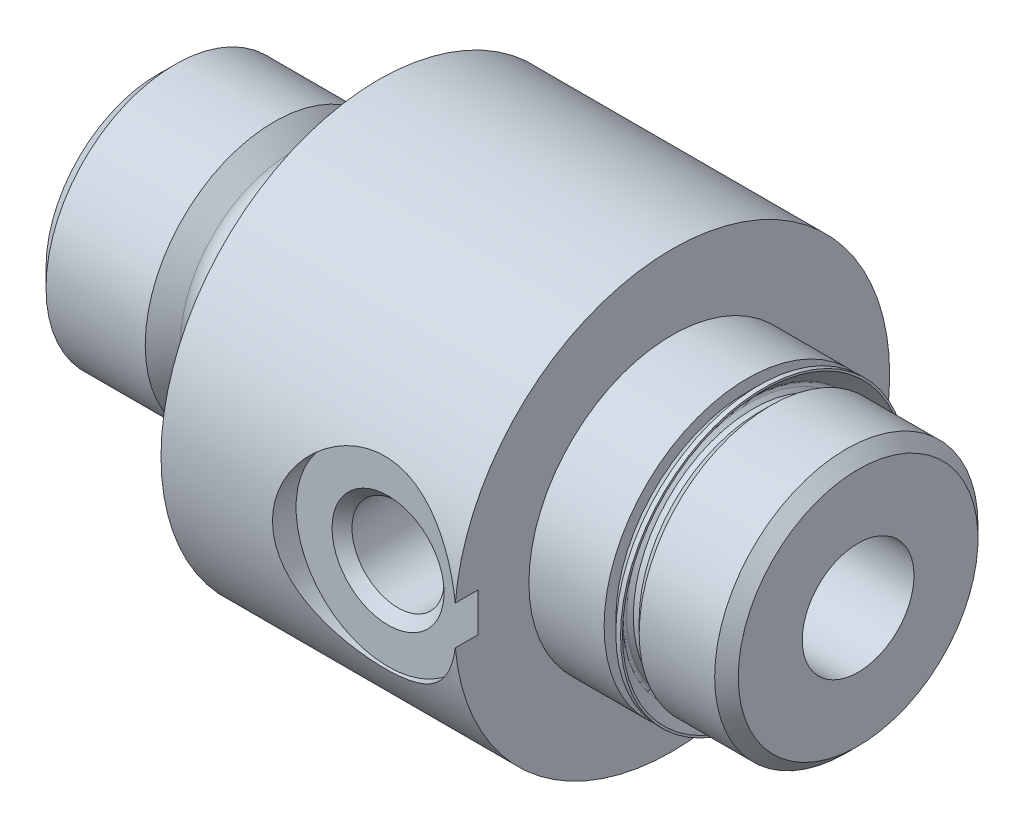
from build123d import *

# Parameters (mm, degrees)
SKETCH5_W = 3.2385
SKETCH5_H = 3.81


with BuildPart() as part:
    # Sketch1 → Revolve1 (revolve)
    with BuildSketch(Plane.XY):
        with BuildLine():
            Line((0, 0), (0, 4.8006))
            Line((0, 4.8006), (0.75565, 5.55625))
            Line((0.75565, 5.55625), (5.028593864, 5.55625))
            Line((5.028593864, 5.55625), (5.786403291, 4.804192648))
            ThreePointArc((5.786403291, 4.804192648), (6.045223575, 4.6323221), (6.35, 4.572))
            Line((6.35, 4.572), (7.5184, 4.572))
            ThreePointArc((7.5184, 4.572), (8.084156136, 4.806343864), (8.3185, 5.3721))
            Line((8.3185, 5.3721), (8.3185, 5.5245))
            Line((8.3185, 5.5245), (9.525, 5.5245))
            Line((9.525, 5.5245), (9.525, 0))
            Line((9.525, 0), (0, 0))
        make_face()
    revolve(axis=Axis((9.525, 0, 0), (-1, 0, 0)))

    # Sketch2 → Revolve2 (revolve)
    with BuildSketch(Plane.XY):
        Polygon((9.525, 0), (9.525, 9.3726), (25.4, 9.3726), (25.4, 5.16255), (25.908, 5.16255), (26.416, 5.67055), (29.6672, 5.67055), (30.1752, 5.16255), (30.1752, 0), align=None)
    revolve(axis=Axis((30.1752, 0, 0), (-1, 0, 0)))

    # Sketch3 → Cut-Revolve1 (revolve, cut)
    with BuildSketch(Plane.XY):
        Polygon((0, 0), (0, 2.91465), (0.508, 2.40665), (30.1752, 2.40665), (30.1752, 0), align=None)
    revolve(axis=Axis((30.1752, 0, 0), (-1, 0, 0)), mode=Mode.SUBTRACT)

    # Sketch4 → Cut-Revolve2 (revolve, cut)
    with BuildSketch(Plane(origin=(0, 0, 0), x_dir=(1, 0, 0), z_dir=(0, 1, 0))):
        Polygon((18.288, 1.016), (20.27174, 1.016), (20.27174, -7.92734), (20.701, -8.3566), (22.2504, -8.3566), (22.2504, -9.3726), (18.288, -9.3726), align=None)
    revolve(axis=Axis((18.288, 0, 9.3726), (0, 0, -1)), mode=Mode.SUBTRACT)

    # Sketch5 → Cut-Revolve3 (revolve, cut)
    with BuildSketch(Plane.XY):
        with Locations((23.78075, 8.07085)):
            Rectangle(SKETCH5_W, SKETCH5_H)
    revolve(axis=Axis((25.4, 0, 0), (-1, 0, 0)), mode=Mode.SUBTRACT)

    # Sketch6 → Revolve3 (revolve)
    with BuildSketch(Plane.XY):
        with BuildLine():
            Line((25.4, 5.660338686), (25.4, 4.90855))
            Line((25.4, 4.90855), (25.908, 4.90855))
            Line((25.908, 4.90855), (25.908, 5.16255))
            Line((25.908, 5.16255), (25.654, 5.16255))
            Line((25.654, 5.16255), (25.511592316, 5.304957684))
            ThreePointArc((25.511592316, 5.304957684), (25.474394878, 5.394760245), (25.511592316, 5.484562806))
            Line((25.511592316, 5.484562806), (26.108711314, 6.081681804))
            Line((26.108711314, 6.081681804), (26.108711314, 6.16585))
            Line((26.108711314, 6.16585), (25.905511314, 6.16585))
            Line((25.905511314, 6.16585), (25.4, 5.660338686))
        make_face()
    revolve(axis=Axis((25.908, 0, 0), (-1, 0, 0)))


solid = part.part
